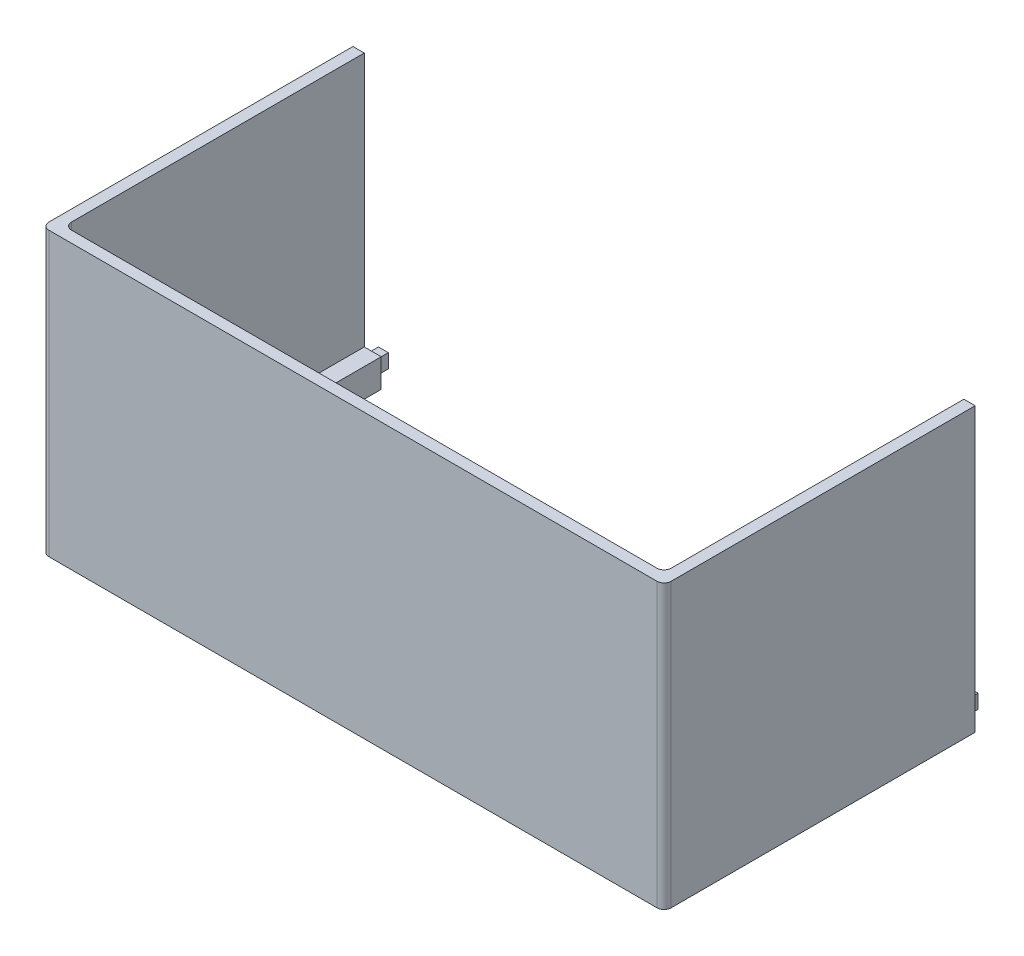
from build123d import *

# Parameters (mm, degrees)
SKETCH1_W           = 139.7
SKETCH1_H           = 154.20848
BOSS_EXTRUDE1_DEPTH = 6.35
SKETCH2_W           = 127
SKETCH2_H           = 141.50848
CUT_EXTRUDE1_DEPTH  = 6.35
SKETCH3_W           = 139.7
SKETCH3_H           = 154.20848
SKETCH3_W_2         = 134.62
SKETCH3_H_2         = 149.12848
BOSS_EXTRUDE2_DEPTH = 57.15
SKETCH4_W           = 139.7
SKETCH4_H           = 84.35848
CUT_EXTRUDE2_DEPTH  = 64.5
SKETCH5_W           = 2.2225
SKETCH5_H           = 3.175
BOSS_EXTRUDE3_DEPTH = 3.175
FILLET1_R           = 1.5875


with BuildPart() as part:
    # Sketch1 → Boss-Extrude1 (new body)
    with BuildSketch(Plane(origin=(0, 0, 0), x_dir=(1, 0, 0), z_dir=(0, 1, 0))):
        Rectangle(SKETCH1_W, SKETCH1_H)
    extrude(amount=BOSS_EXTRUDE1_DEPTH)

    # Sketch2 → Cut-Extrude1 (cut)
    with BuildSketch(Plane(origin=(0, 6.35, 0), x_dir=(1, 0, 0), z_dir=(0, 1, 0))):
        Rectangle(SKETCH2_W, SKETCH2_H)
    extrude(amount=-CUT_EXTRUDE1_DEPTH, mode=Mode.SUBTRACT)

    # Sketch3 → Boss-Extrude2 (add)
    with BuildSketch(Plane(origin=(0, 6.35, 0), x_dir=(1, 0, 0), z_dir=(0, 1, 0))):
        Rectangle(SKETCH3_W, SKETCH3_H)
        Rectangle(SKETCH3_W_2, SKETCH3_H_2, mode=Mode.SUBTRACT)
    extrude(amount=BOSS_EXTRUDE2_DEPTH)

    # Sketch4 → Cut-Extrude2 (cut, through all)
    with BuildSketch(Plane(origin=(0, 63.5, 0), x_dir=(1, 0, 0), z_dir=(0, 1, 0))):
        with Locations((0, 34.925)):
            Rectangle(SKETCH4_W, SKETCH4_H)
    extrude(amount=-CUT_EXTRUDE2_DEPTH, mode=Mode.SUBTRACT)

    # Sketch5 → Boss-Extrude3 (add)
    with BuildSketch(Plane(origin=(0, 0, 7.25424), x_dir=(-1, 0, 0), z_dir=(0, 0, -1))):
        with Locations((-66.19875, 3.175)):
            Rectangle(SKETCH5_W, SKETCH5_H)
        with Locations((66.19875, 3.175)):
            Rectangle(SKETCH5_W, SKETCH5_H)
    extrude(amount=BOSS_EXTRUDE3_DEPTH)

    # Fillet1
    fillet1_edges = [part.edges().sort_by_distance(p)[0] for p in [
        (-67.31, 34.925, 74.56424),
        (67.31, 34.925, 74.56424),
        (69.85, 31.75, 77.10424),
        (-69.85, 31.75, 77.10424),
    ]]
    fillet(fillet1_edges, radius=FILLET1_R)


solid = part.part
